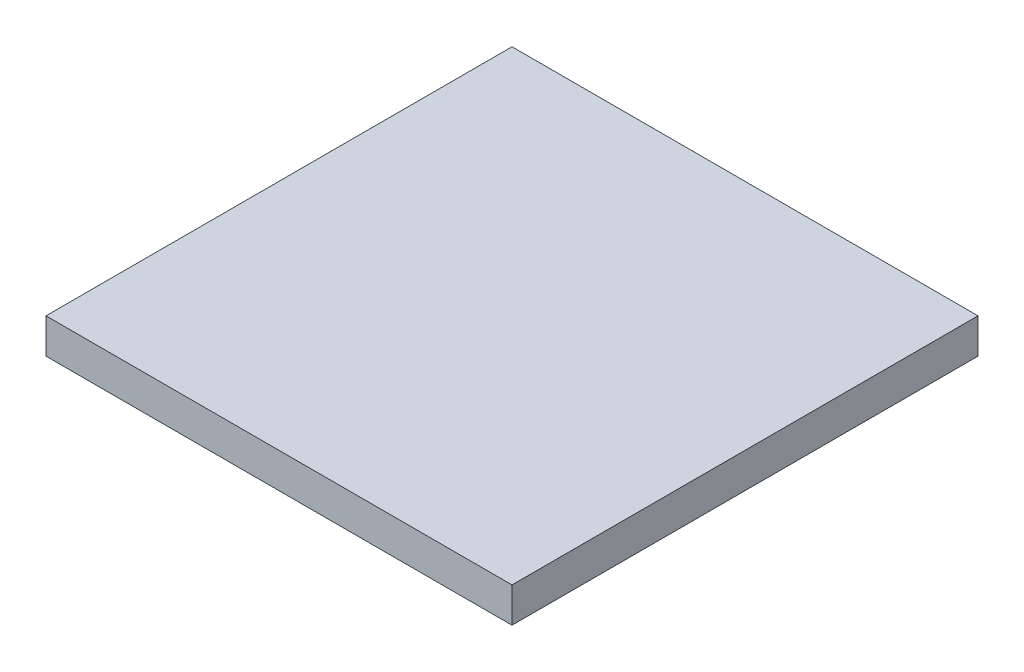
from build123d import *

# Parameters (mm, degrees)
SKETCH_1_W      = 20
SKETCH_1_H      = 20
EXTRUDE_1_DEPTH = 1.5


with BuildPart() as part:
    # Эскиз1 → Бобышка-Вытянуть1 (new body)
    with BuildSketch(Plane(origin=(0, 0, 0), x_dir=(1, 0, 0), z_dir=(0, 1, 0))):
        with Locations((1.61971831, 5)):
            Rectangle(SKETCH_1_W, SKETCH_1_H)
    extrude(amount=EXTRUDE_1_DEPTH)


solid = part.part
